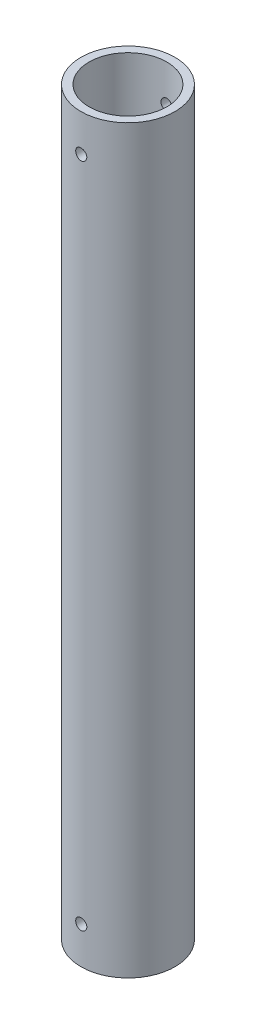
from build123d import *

# Parameters (mm, degrees)
CROQUIS1_R                 = 12.7
CROQUIS1_R_2               = 10.5
SALIENTE_EXTRUIR1_DEPTH    = 200
CROQUIS2_R                 = 1.5
CORTAR_EXTRUIR1_DEPTH      = 13.7
CORTAR_EXTRUIR1_DEPTH_BACK = 13.7


with BuildPart() as part:
    # Croquis1 → Saliente-Extruir1 (new body)
    with BuildSketch(Plane(origin=(0, 0, 0), x_dir=(1, 0, 0), z_dir=(0, 1, 0))):
        Circle(CROQUIS1_R)
        Circle(CROQUIS1_R_2, mode=Mode.SUBTRACT)
    extrude(amount=SALIENTE_EXTRUIR1_DEPTH)

    # Croquis2 → Cortar-Extruir1 (cut, two sides)
    with BuildSketch(Plane.XY) as cortar_extruir1_sk:
        with Locations((0, 190)):
            Circle(CROQUIS2_R)
        with Locations((0, 10)):
            Circle(CROQUIS2_R)
    extrude(amount=CORTAR_EXTRUIR1_DEPTH, mode=Mode.SUBTRACT)
    extrude(cortar_extruir1_sk.sketch, amount=-CORTAR_EXTRUIR1_DEPTH_BACK, mode=Mode.SUBTRACT)


solid = part.part
